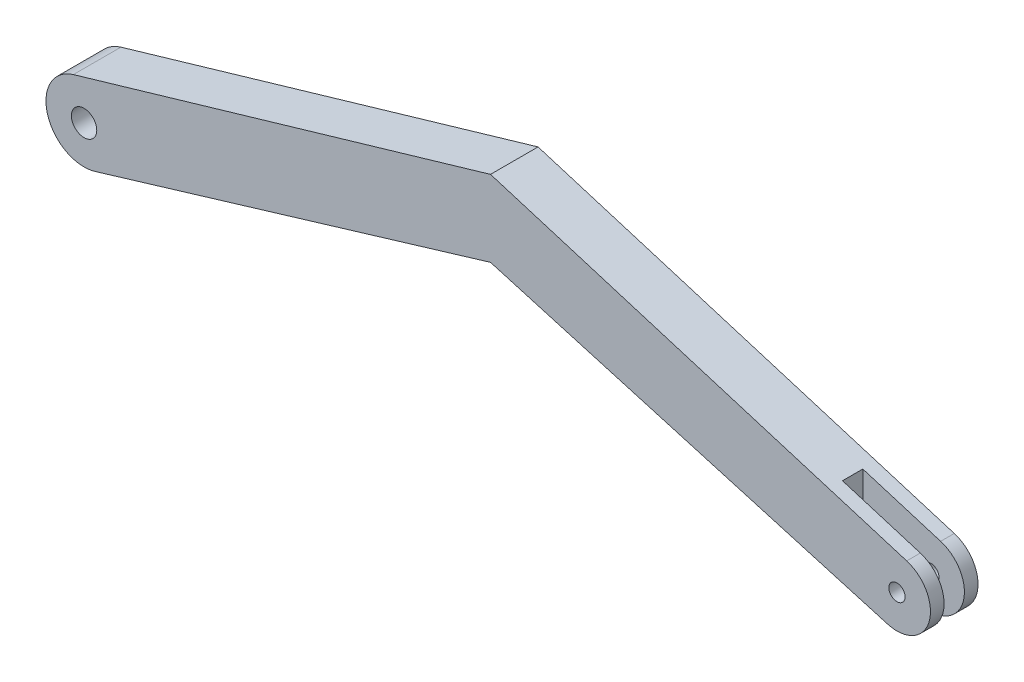
from build123d import *

# Parameters (mm, degrees)
SKETCH1_R               = 0.79375
BOSS_EXTRUDE1_DEPTH     = 2.9718
CUT_EXTRUDE1_DEPTH      = 55.179945312
CUT_EXTRUDE1_DEPTH_BACK = 55.179945312
SKETCH2_W               = 8.538559206
SKETCH2_H               = 1.27
CUT_EXTRUDE3_DEPTH      = 55.179945312
CUT_EXTRUDE3_DEPTH_BACK = 55.179945312
SKETCH1_4_R             = 0.508


with BuildPart() as part:
    # Sketch1 → Boss-Extrude1 (new body)
    with BuildSketch(Plane.XY):
        with BuildLine():
            ThreePointArc((-51.469201485, 2.285283557), (-53.082780246, -0.677691603), (-50.113827643, -2.280245394))
            Line((-50.113827643, -2.280245394), (-25.4, 5.156649519))
            Line((-25.4, 5.156649519), (-0.581588952, -2.013175239))
            ThreePointArc((-0.581588952, -2.013175239), (2.009011043, -0.595814467), (0.610010171, 2.004746329))
            Line((0.610010171, 2.004746329), (-25.4, 9.919149519))
            Line((-25.4, 9.919149519), (-51.469201485, 2.285283557))
        make_face()
        with Locations((-50.8, 0)):
            Circle(SKETCH1_R, mode=Mode.SUBTRACT)
    extrude(amount=BOSS_EXTRUDE1_DEPTH)

    # Sketch2 → Cut-Extrude1 (cut, two sides: drawn at the far end of the back side and taken through both)
    with BuildSketch(Plane(origin=(0, 0, 0), x_dir=(1, 0, 0), z_dir=(0, 1, 0)).offset(-CUT_EXTRUDE1_DEPTH_BACK)):
        with Locations((0.014779603, -1.4859)):
            Rectangle(SKETCH2_W, SKETCH2_H)
    extrude(amount=CUT_EXTRUDE1_DEPTH + CUT_EXTRUDE1_DEPTH_BACK, mode=Mode.SUBTRACT)

    # Sketch1_4 → Cut-Extrude3 (cut, two sides: drawn at the far end of the back side and taken through both)
    with BuildSketch(Plane.XY.offset(-CUT_EXTRUDE3_DEPTH_BACK)):
        Circle(SKETCH1_4_R)
    extrude(amount=CUT_EXTRUDE3_DEPTH + CUT_EXTRUDE3_DEPTH_BACK, mode=Mode.SUBTRACT)


solid = part.part
